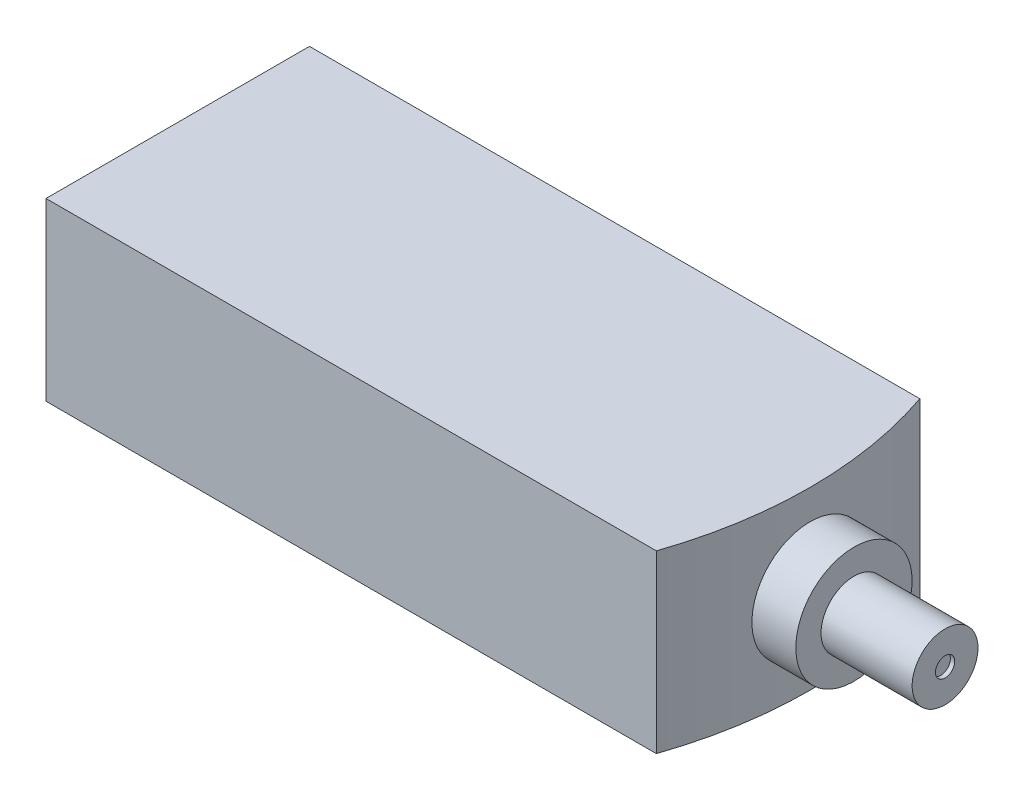
from build123d import *

# Parameters (mm, degrees)
SKETCH1_W           = 349.5
SKETCH1_H           = 120
BOSS_EXTRUDE1_DEPTH = 80
SKETCH2_W           = 41.5
SKETCH2_H           = 120
CUT_EXTRUDE1_DEPTH  = 81
CUT_EXTRUDE4_DEPTH  = 80
SKETCH4_R           = 26.482881768
BOSS_EXTRUDE2_DEPTH = 20
SKETCH5_R           = 15
BOSS_EXTRUDE3_DEPTH = 41.5
SKETCH6_R           = 7.5
BOSS_EXTRUDE4_DEPTH = 8.5
SKETCH7_R           = 3
SKETCH7_R_2         = 2
CUT_EXTRUDE5_DEPTH  = 10
SKETCH8_R           = 4.405750712
CUT_EXTRUDE6_DEPTH  = 2


with BuildPart() as part:
    # Sketch1 → Boss-Extrude1 (new body)
    with BuildSketch(Plane(origin=(0, 0, 0), x_dir=(1, 0, 0), z_dir=(0, 1, 0))):
        with Locations((-79.585339158, 42.428164832)):
            Rectangle(SKETCH1_W, SKETCH1_H)
    extrude(amount=BOSS_EXTRUDE1_DEPTH)

    # Sketch2 → Cut-Extrude1 (cut, through all)
    with BuildSketch(Plane(origin=(0, 80, 0), x_dir=(1, 0, 0), z_dir=(0, 1, 0))):
        with Locations((74.414660842, 42.428164832)):
            Rectangle(SKETCH2_W, SKETCH2_H)
    extrude(amount=-CUT_EXTRUDE1_DEPTH, mode=Mode.SUBTRACT)

    # Sketch3 → Cut-Extrude4 (cut)
    with BuildSketch(Plane(origin=(0, 80, 0), x_dir=(1, 0, 0), z_dir=(0, 1, 0))):
        with BuildLine():
            Line((53.664660842, 102.428164832), (23.664660842, 102.428164832))
            ThreePointArc((23.664660842, 102.428164832), (33.664660842, 42.428164832), (23.664660842, -17.571835168))
            Line((23.664660842, -17.571835168), (53.664660842, -17.571835168))
            Line((53.664660842, -17.571835168), (53.664660842, 102.428164832))
        make_face()
    extrude(amount=-CUT_EXTRUDE4_DEPTH, mode=Mode.SUBTRACT)

    # Sketch6 → Boss-Extrude4 (add)
    with BuildSketch(Plane.ZY.offset(254.335339158)):
        with Locations(Location((-70.807073687, 44.689651379, 0), (0, 0, 180))):  # turned: the seam where the file's is
            Circle(SKETCH6_R)
    extrude(amount=BOSS_EXTRUDE4_DEPTH)

    # Sketch7 → Cut-Extrude5 (cut)
    with BuildSketch(Plane.XZ):
        with Locations(Location((-142.335339158, -42.428164832, 0), (0, 0, 270))):  # turned: the seam where the file's is
            Circle(SKETCH7_R)
        with Locations(Location((-57.335339158, -42.428164832, 0), (0, 0, 270))):  # turned: the seam where the file's is
            Circle(SKETCH7_R)
        with Locations(Location((-129.835339158, -42.428164832, 0), (0, 0, 270))):  # turned: the seam where the file's is
            Circle(SKETCH7_R_2)
        with Locations(Location((-69.835339158, -42.428164832, 0), (0, 0, 270))):  # turned: the seam where the file's is
            Circle(SKETCH7_R_2)
    extrude(amount=-CUT_EXTRUDE5_DEPTH, mode=Mode.SUBTRACT)


with BuildPart() as body_2:
    # Sketch4 → Boss-Extrude2 (new body)
    with BuildSketch(Plane(origin=(33.664660842, 0, 0), x_dir=(0, 0, -1), z_dir=(1, 0, 0))):
        with Locations((42.428164832, 40)):
            Circle(SKETCH4_R)
    extrude(amount=BOSS_EXTRUDE2_DEPTH)

    # Sketch5 → Boss-Extrude3 (add)
    with BuildSketch(Plane(origin=(53.664660842, 0, 0), x_dir=(0, 0, -1), z_dir=(1, 0, 0))):
        with Locations((42.428164832, 40)):
            Circle(SKETCH5_R)
    extrude(amount=BOSS_EXTRUDE3_DEPTH)

    # Sketch8 → Cut-Extrude6 (cut)
    with BuildSketch(Plane(origin=(95.164660842, 0, 0), x_dir=(0, 0, -1), z_dir=(1, 0, 0))):
        with Locations((42.428164832, 40)):
            Circle(SKETCH8_R)
    extrude(amount=-CUT_EXTRUDE6_DEPTH, mode=Mode.SUBTRACT)


solid = Compound([part.part, body_2.part])
